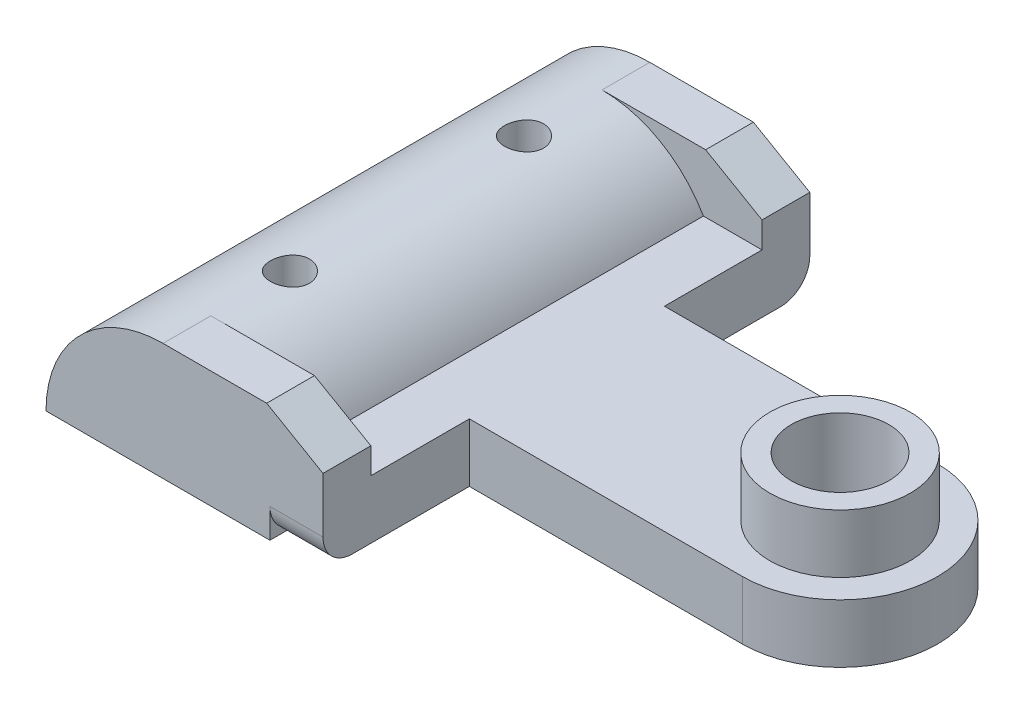
from build123d import *

# Parameters (mm, degrees)
CROQUIS1_R              = 2.500000266
CROQUIS1_R_2            = 1.000000047
CROQUIS1_R_3            = 1.000000141
SALIENTE_EXTRUIR1_DEPTH = 3
SALIENTE_EXTRUIR2_DEPTH = 24.95
CROQUIS3_W              = 8.200000763
CROQUIS3_H              = 2.45
SALIENTE_EXTRUIR3_DEPTH = 3
CORTAR_EXTRUIR1_DEPTH   = 31
CORTAR_EXTRUIR2_DEPTH   = 2.72
CROQUIS6_R              = 3.6
CROQUIS6_R_2            = 2.500000266
SALIENTE_EXTRUIR4_DEPTH = 3
CORTAR_EXTRUIR3_DEPTH   = 27
CROQUIS8_R              = 1.000000047
CROQUIS8_R_2            = 1.000000141
CORTAR_EXTRUIR4_DEPTH   = 27


with BuildPart() as part:
    # Croquis1 → Saliente-Extruir1 (new body)
    with BuildSketch(Plane(origin=(0, 0, 0), x_dir=(1, 0, 0), z_dir=(0, 1, 0))):
        with BuildLine():
            Line((-16.847731683, 12.84659639), (-2.64773092, 12.84659639))
            Line((-2.64773092, 12.84659639), (-2.64773092, 5.396596581))
            Line((-2.64773092, 5.396596581), (11.352269703, 5.396596581))
            ThreePointArc((11.352269703, 5.396596581), (16.352269703, 0.396596581), (11.352269703, -4.603403419))
            Line((11.352269703, -4.603403419), (-2.64773092, -4.603403419))
            Line((-2.64773092, -4.603403419), (-2.64773092, -12.103403419))
            Line((-2.64773092, -12.103403419), (-16.847731683, -12.103403419))
            Line((-16.847731683, -12.103403419), (-16.847731683, 12.84659639))
        make_face()
        with Locations((11.352269089, 0.39659652)):
            Circle(CROQUIS1_R, mode=Mode.SUBTRACT)
        with Locations((-10.847731494, 6.396596534)):
            Circle(CROQUIS1_R_2, mode=Mode.SUBTRACT)
        with Locations((-10.847730816, -5.603403561)):
            Circle(CROQUIS1_R_3, mode=Mode.SUBTRACT)
    extrude(amount=SALIENTE_EXTRUIR1_DEPTH)

    # Croquis2 → Saliente-Extruir2 (add)
    with BuildSketch(Plane.XY.offset(12.103403419)):
        with BuildLine():
            Line((-16.043884106, 3), (-5.651579261, 3))
            ThreePointArc((-5.651579261, 3), (-10.847731683, 6), (-16.043884106, 3))
        make_face()
    extrude(amount=-SALIENTE_EXTRUIR2_DEPTH)

    # Croquis3 → Saliente-Extruir3 (add)
    with BuildSketch(Plane(origin=(0, 3, 0), x_dir=(1, 0, 0), z_dir=(0, 1, 0))):
        with Locations((-6.747731302, 11.62159639)):
            Rectangle(CROQUIS3_W, CROQUIS3_H)
        with Locations((-6.747731302, -10.878403419)):
            Rectangle(CROQUIS3_W, CROQUIS3_H)
    extrude(amount=SALIENTE_EXTRUIR3_DEPTH)

    # Croquis4 → Cortar-Extruir1 (cut)
    with BuildSketch(Plane.XY.offset(12.103403419)):
        Polygon((-2.64773092, 4.33), (-2.64773092, 6), (-5.53773092, 6), align=None)
    extrude(amount=-CORTAR_EXTRUIR1_DEPTH, mode=Mode.SUBTRACT)

    # Croquis5 → Cortar-Extruir2 (cut)
    with BuildSketch(Plane(origin=(-2.64773092, 0, 0), x_dir=(0, 0, -1), z_dir=(1, 0, 0))):
        with BuildLine():
            Line((12.84659639, 1.5), (14.964292121, 1.5))
            ThreePointArc((14.964292121, 1.5), (0, -14.850313202), (-14.964292121, 1.5))
            Line((-14.964292121, 1.5), (-12.103403419, 1.5))
            ThreePointArc((-12.103403419, 1.5), (-11.664063591, 0.439339828), (-10.603403419, 0))
            Line((-10.603403419, 0), (11.34659639, 0))
            ThreePointArc((11.34659639, 0), (12.407256562, 0.439339828), (12.84659639, 1.5))
        make_face()
    extrude(amount=-CORTAR_EXTRUIR2_DEPTH, mode=Mode.SUBTRACT)

    # Croquis6 → Saliente-Extruir4 (add)
    with BuildSketch(Plane(origin=(0, 3, 0), x_dir=(1, 0, 0), z_dir=(0, 1, 0))):
        with Locations((11.352269089, 0.39659652)):
            Circle(CROQUIS6_R)
        with Locations((11.352269089, 0.39659652)):
            Circle(CROQUIS6_R_2, mode=Mode.SUBTRACT)
    extrude(amount=SALIENTE_EXTRUIR4_DEPTH)

    # Croquis7 → Cortar-Extruir3 (cut)
    with BuildSketch(Plane.XY.offset(12.103403419)):
        with BuildLine():
            Line((-12.758872324, 7.288729336), (-12.369518171, 5.803806155))
            ThreePointArc((-12.369518171, 5.803806155), (-15.59803267, 3.665329526), (-16.847731683, 0))
            Line((-16.847731683, 0), (-18.382851714, 0))
            ThreePointArc((-18.382851714, 0), (-16.813413036, 4.603116322), (-12.758872324, 7.288729336))
        make_face()
    extrude(amount=-CORTAR_EXTRUIR3_DEPTH, mode=Mode.SUBTRACT)

    # Croquis8 → Cortar-Extruir4 (cut)
    with BuildSketch(Plane.XZ):
        with Locations((-10.847731494, -6.396596534)):
            Circle(CROQUIS8_R)
        with Locations((-10.847730816, 5.603403561)):
            Circle(CROQUIS8_R_2)
    extrude(amount=-CORTAR_EXTRUIR4_DEPTH, mode=Mode.SUBTRACT)


solid = part.part
